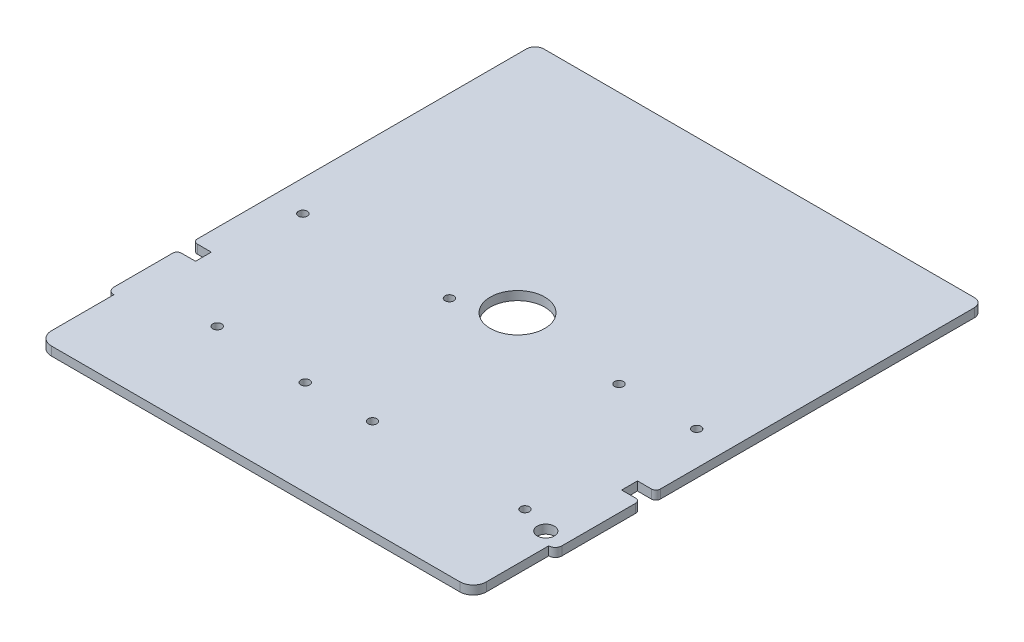
from build123d import *

# Parameters (mm, degrees)
BOSS_EXTRUDE1_DEPTH     = 1
SKETCH2_W               = 2.1
SKETCH2_H               = 1.8
CUT_EXTRUDE1_DEPTH      = 1
CUT_EXTRUDE1_DEPTH_BACK = 2
FILLET1_R               = 0.5
SKETCH3_R               = 0.5
SKETCH3_R_2             = 0.975
CUT_EXTRUDE2_DEPTH      = 1
CUT_EXTRUDE2_DEPTH_BACK = 2


with BuildPart() as part:
    # Sketch1 → Boss-Extrude1 (new body)
    with BuildSketch(Plane(origin=(0, 0, 0), x_dir=(1, 0, 0), z_dir=(0, 1, 0))):
        with BuildLine():
            Line((0, -1), (0, -21.45))
            ThreePointArc((0, -21.45), (0.219669914, -21.980330086), (0.75, -22.2))
            Line((0.75, -22.2), (0.75, -29.3))
            ThreePointArc((0.75, -29.3), (1.189339828, -30.360660172), (2.25, -30.8))
            Line((2.25, -30.8), (48.75, -30.8))
            ThreePointArc((48.75, -30.8), (49.810660172, -30.360660172), (50.25, -29.3))
            Line((50.25, -29.3), (50.25, -22.2))
            ThreePointArc((50.25, -22.2), (50.780330086, -21.980330086), (51, -21.45))
            Line((51, -21.45), (51, -1))
            Line((51, -1), (51, 25.5))
            ThreePointArc((51, 25.5), (50.707106781, 26.207106781), (50, 26.5))
            Line((50, 26.5), (1, 26.5))
            ThreePointArc((1, 26.5), (0.292893219, 26.207106781), (0, 25.5))
            Line((0, 25.5), (0, -1))
        make_face()
    extrude(amount=BOSS_EXTRUDE1_DEPTH)

    # Sketch2 → Cut-Extrude1 (cut, two sides)
    with BuildSketch(Plane(origin=(0, 1, 0), x_dir=(1, 0, 0), z_dir=(0, 1, 0))) as cut_extrude1_sk:
        with Locations((1.05, -13.35)):
            Rectangle(SKETCH2_W, SKETCH2_H)
        with BuildLine():
            ThreePointArc((22.4, -1), (25.5, -4.1), (28.6, -1))
            ThreePointArc((28.6, -1), (25.5, 2.1), (22.4, -1))
        make_face()
        with Locations((49.95, -11.65)):
            Rectangle(SKETCH2_W, SKETCH2_H)
    extrude(amount=CUT_EXTRUDE1_DEPTH, mode=Mode.SUBTRACT)
    extrude(cut_extrude1_sk.sketch, amount=-CUT_EXTRUDE1_DEPTH_BACK, mode=Mode.SUBTRACT)

    # Fillet1
    fillet1_edges = [part.edges().sort_by_distance(p)[0] for p in [
        (0, 0.5, 14.25),
        (0, 0.5, 12.45),
        (51, 0.5, 10.75),
        (51, 0.5, 12.55),
    ]]
    fillet(fillet1_edges, radius=FILLET1_R)

    # Sketch3 → Cut-Extrude2 (cut, two sides)
    with BuildSketch(Plane(origin=(0, 1, 0), x_dir=(1, 0, 0), z_dir=(0, 1, 0))) as cut_extrude2_sk:
        with Locations((3.52, -3.45)):
            Circle(SKETCH3_R)
        with Locations((20.2, -3.45)):
            Circle(SKETCH3_R)
        with Locations((38.3, -2.25)):
            Circle(SKETCH3_R)
        with Locations((47.14, -2.25)):
            Circle(SKETCH3_R)
        with Locations((48.627, -20.91)):
            Circle(SKETCH3_R_2)
        with Locations((45.29, -19.95)):
            Circle(SKETCH3_R)
        with Locations((27.94, -19.95)):
            Circle(SKETCH3_R)
        with Locations((20.29, -19.95)):
            Circle(SKETCH3_R)
        with Locations((9.75, -19.43)):
            Circle(SKETCH3_R)
    extrude(amount=CUT_EXTRUDE2_DEPTH, mode=Mode.SUBTRACT)
    extrude(cut_extrude2_sk.sketch, amount=-CUT_EXTRUDE2_DEPTH_BACK, mode=Mode.SUBTRACT)


solid = part.part
